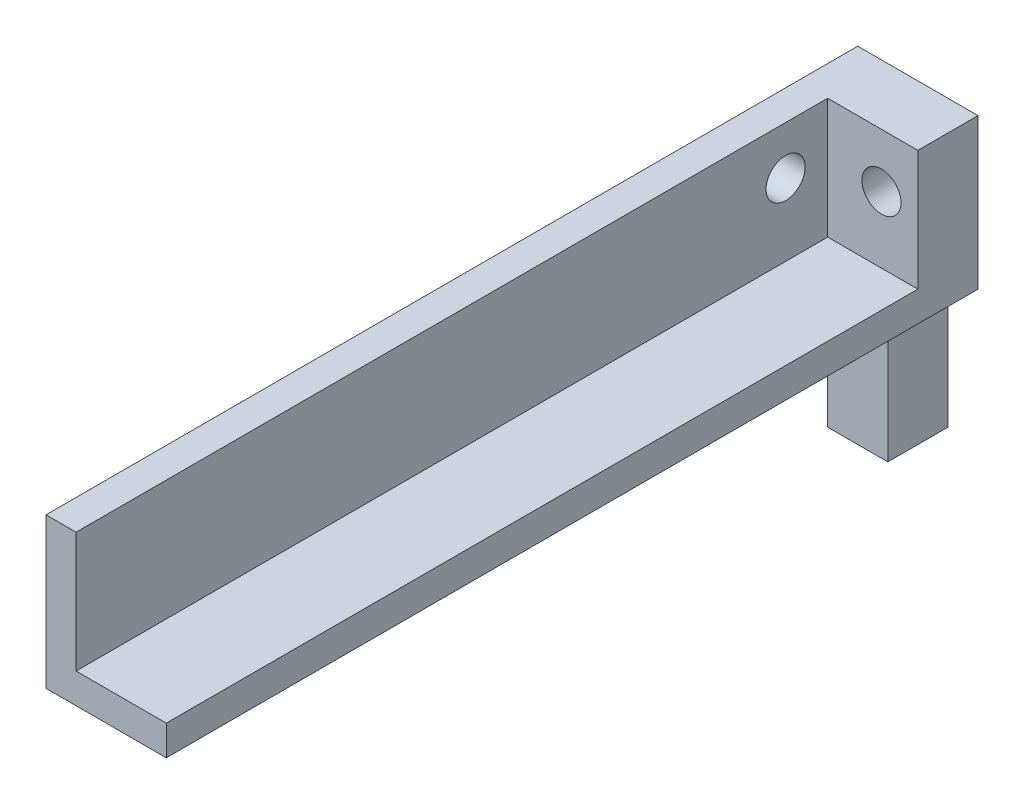
from build123d import *

# Parameters (mm, degrees)
BOSS_EXTRUDE1_DEPTH      = 10
SKETCH2_W                = 30
SKETCH2_H                = 25
BOSS_EXTRUDE2_DEPTH      = 5
BOSS_EXTRUDE3_DEPTH      = 5
BOSS_EXTRUDE4_DEPTH      = 105
SKETCH7_R                = 3.25
CUT_EXTRUDE10_DEPTH      = 15
CUT_EXTRUDE10_DEPTH_BACK = 13
SKETCH8_R                = 3.25
CUT_EXTRUDE11_DEPTH      = 17
CUT_EXTRUDE11_DEPTH_BACK = 14


with BuildPart() as part:
    # Sketch1 → Boss-Extrude1 (new body)
    with BuildSketch(Plane(origin=(0, 0, 0), x_dir=(0, 0, -1), z_dir=(1, 0, 0))):
        Polygon((0, 0), (-10, 0), (-10, -20), (-30, -20), (-30, -25), (-10, -25), (-10, -47.38), (0, -47.38), align=None)
    extrude(amount=BOSS_EXTRUDE1_DEPTH)

    # Sketch2 → Boss-Extrude2 (add)
    with BuildSketch(Plane.ZY):
        with Locations((15, -12.5)):
            Rectangle(SKETCH2_W, SKETCH2_H)
    extrude(amount=BOSS_EXTRUDE2_DEPTH)

    # Sketch3 → Boss-Extrude3 (add)
    with BuildSketch(Plane(origin=(10, 0, 0), x_dir=(0, 0, -1), z_dir=(1, 0, 0))):
        Polygon((-10, 0), (-10, -20), (-30, -20), (-30, -25), (-10, -25), (0, -25), (0, 0), align=None)
    extrude(amount=BOSS_EXTRUDE3_DEPTH)

    # Sketch4 → Boss-Extrude4 (add)
    with BuildSketch(Plane.XY.offset(30)):
        Polygon((-5, 0), (-5, -25), (15, -25), (15, -20), (0, -20), (0, 0), align=None)
    extrude(amount=BOSS_EXTRUDE4_DEPTH)

    # Sketch7 → Cut-Extrude10 (cut, two sides)
    with BuildSketch(Plane(origin=(0, 0, 0), x_dir=(-1, 0, 0), z_dir=(0, 0, -1))) as cut_extrude10_sk:
        with Locations((-8.955912711, -8.964075593)):
            Circle(SKETCH7_R)
    extrude(amount=CUT_EXTRUDE10_DEPTH, mode=Mode.SUBTRACT)
    extrude(cut_extrude10_sk.sketch, amount=-CUT_EXTRUDE10_DEPTH_BACK, mode=Mode.SUBTRACT)

    # Sketch8 → Cut-Extrude11 (cut, two sides)
    with BuildSketch(Plane.ZY.offset(5)) as cut_extrude11_sk:
        with Locations((17, -8)):
            Circle(SKETCH8_R)
    extrude(amount=CUT_EXTRUDE11_DEPTH, mode=Mode.SUBTRACT)
    extrude(cut_extrude11_sk.sketch, amount=-CUT_EXTRUDE11_DEPTH_BACK, mode=Mode.SUBTRACT)


solid = part.part
